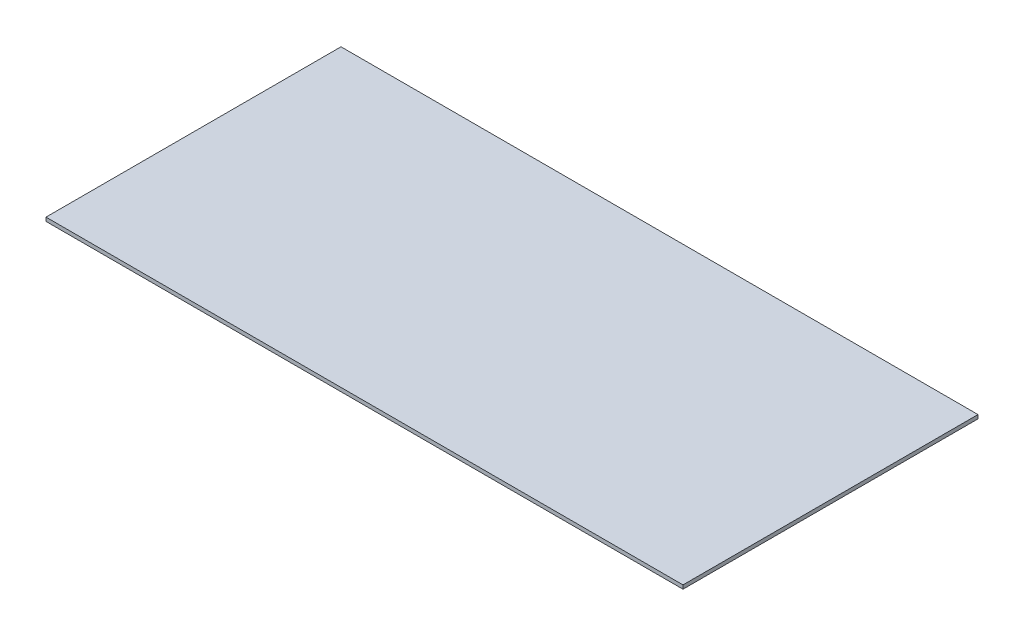
from build123d import *

# Parameters (mm, degrees)
SKETCH1_W   = 1076.325
SKETCH1_H   = 498.475
GLASS_DEPTH = 6.35


with BuildPart() as part:
    # Sketch1 → Glass (new body)
    with BuildSketch(Plane(origin=(0, 0, 0), x_dir=(1, 0, 0), z_dir=(0, 1, 0))):
        Rectangle(SKETCH1_W, SKETCH1_H)
    extrude(amount=GLASS_DEPTH)


solid = part.part
